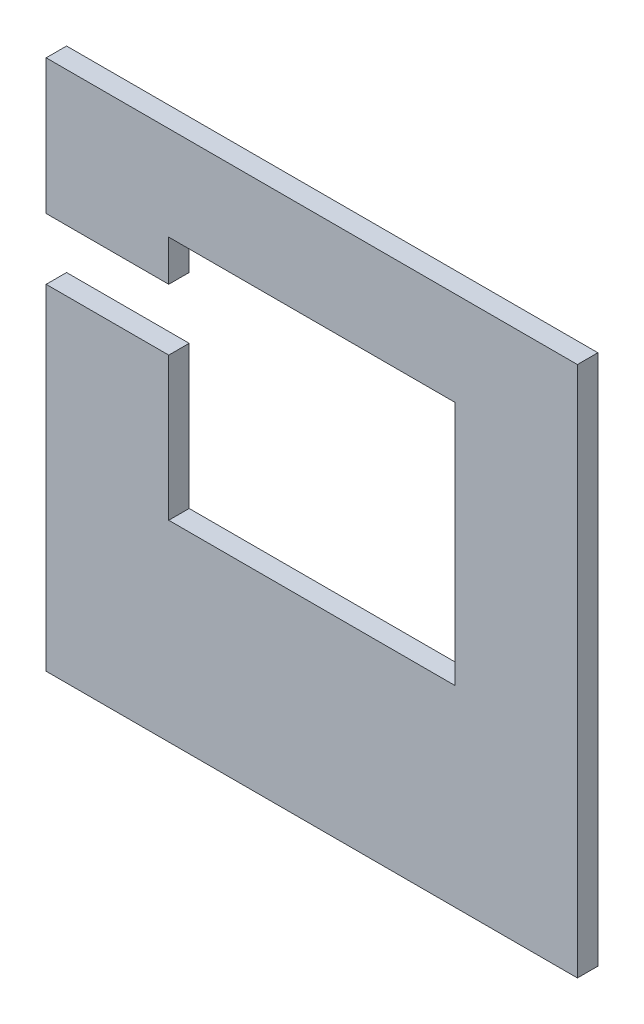
from build123d import *

# Parameters (mm, degrees)
SCHIZZO1_W                   = 130
SCHIZZO1_H                   = 130
ESTRUSIONE_ESTRUSIONE1_DEPTH = 5
SCHIZZO2_W                   = 70
SCHIZZO2_H                   = 60
TAGLIO_ESTRUSIONE1_DEPTH     = 5
SCHIZZO3_W                   = 30
SCHIZZO3_H                   = 15
TAGLIO_ESTRUSIONE2_DEPTH     = 10


with BuildPart() as part:
    # Schizzo1 → Estrusione-Estrusione1 (new body)
    with BuildSketch(Plane.XY):
        Rectangle(SCHIZZO1_W, SCHIZZO1_H)
    extrude(amount=ESTRUSIONE_ESTRUSIONE1_DEPTH)

    # Schizzo2 → Taglio-Estrusione1 (cut)
    with BuildSketch(Plane.XY.offset(5)):
        with Locations((0, 12)):
            Rectangle(SCHIZZO2_W, SCHIZZO2_H)
    extrude(amount=-TAGLIO_ESTRUSIONE1_DEPTH, mode=Mode.SUBTRACT)

    # Schizzo3 → Taglio-Estrusione2 (cut)
    with BuildSketch(Plane.XY.offset(5)):
        with Locations((-50, 24.5)):
            Rectangle(SCHIZZO3_W, SCHIZZO3_H)
    extrude(amount=-TAGLIO_ESTRUSIONE2_DEPTH, mode=Mode.SUBTRACT)


solid = part.part
